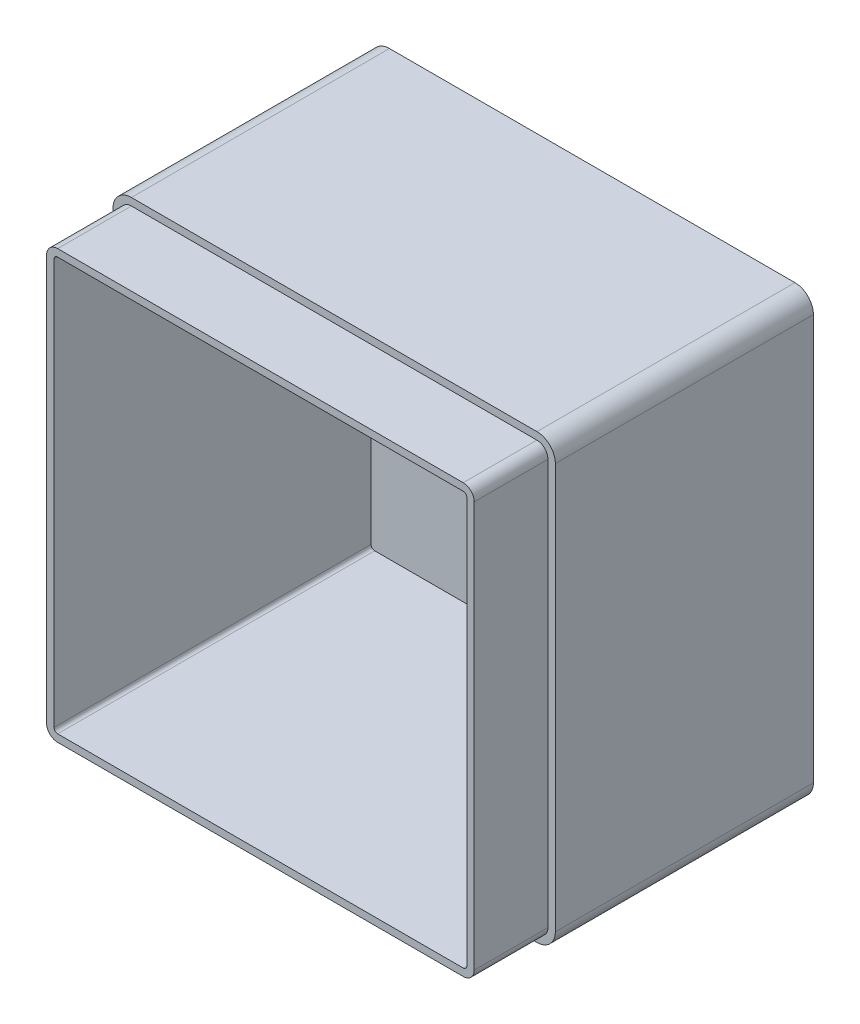
from build123d import *

# Parameters (mm, degrees)
SKETCH1_W           = 120
SKETCH1_H           = 120
BOSS_EXTRUDE1_DEPTH = 90
FILLET1_R           = 5
SHELL1_T            = -4
CUT_EXTRUDE2_DEPTH  = 20


with BuildPart() as part:
    # Sketch1 → Boss-Extrude1 (new body)
    with BuildSketch(Plane.XY):
        with Locations((60, 60)):
            Rectangle(SKETCH1_W, SKETCH1_H)
    extrude(amount=BOSS_EXTRUDE1_DEPTH)

    # Fillet1
    fillet1_edges = [part.edges().sort_by_distance(p)[0] for p in [
        (0, 120, 45),
        (120, 120, 45),
        (120, 0, 45),
        (0, 0, 45),
    ]]
    fillet(fillet1_edges, radius=FILLET1_R)

    # Shell1
    shell1_openings = [part.faces().sort_by_distance(p)[0] for p in [
        (60, 60, 90),
    ]]
    offset(amount=SHELL1_T, openings=shell1_openings, kind=Kind.INTERSECTION)

    # Sketch8 → Cut-Extrude2 (cut)
    with BuildSketch(Plane.XY.offset(90)):
        with BuildLine():
            Line((120, 5), (120, 115))
            ThreePointArc((120, 115), (118.535533906, 118.535533906), (115, 120))
            Line((115, 120), (5, 120))
            ThreePointArc((5, 120), (1.464466094, 118.535533906), (0, 115))
            Line((0, 115), (0, 5))
            ThreePointArc((0, 5), (1.464466094, 1.464466094), (5, 0))
            Line((5, 0), (115, 0))
            ThreePointArc((115, 0), (118.535533906, 1.464466094), (120, 5))
        make_face()
        with BuildLine():
            Line((118, 5), (118, 115))
            ThreePointArc((118, 115), (117.121320344, 117.121320344), (115, 118))
            Line((115, 118), (5, 118))
            ThreePointArc((5, 118), (2.878679656, 117.121320344), (2, 115))
            Line((2, 115), (2, 5))
            ThreePointArc((2, 5), (2.878679656, 2.878679656), (5, 2))
            Line((5, 2), (115, 2))
            ThreePointArc((115, 2), (117.121320344, 2.878679656), (118, 5))
        make_face(mode=Mode.SUBTRACT)
    extrude(amount=-CUT_EXTRUDE2_DEPTH, mode=Mode.SUBTRACT)


solid = part.part
